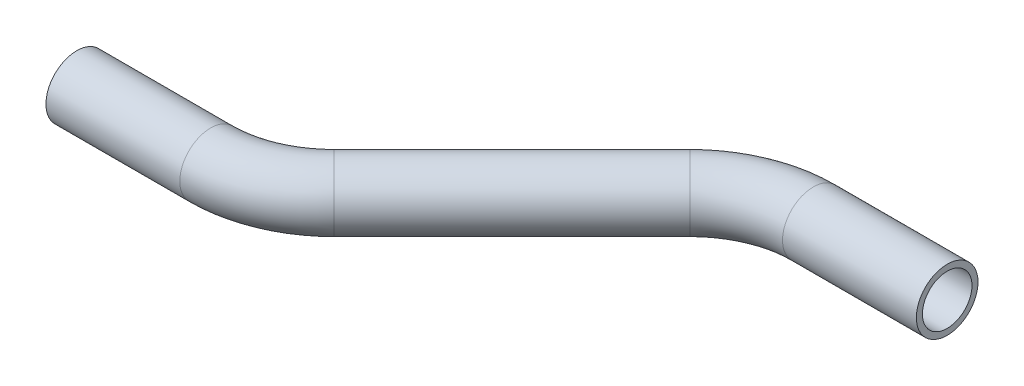
from build123d import *

# Parameters (mm, degrees)
SKETCH3_R   = 6.35
SKETCH3_R_2 = 5.1054


with BuildPart() as part:
    # Sweep1: sweep along a path in Sketch2
    with BuildLine(Plane(origin=(0, 0, 0), x_dir=(1, 0, 0), z_dir=(0, 1, 0))) as sweep1_path:
        Line((0, 0), (27.578975516, 0))
        ThreePointArc((27.578975516, 0), (37.299134698, 1.933459874), (45.539487758, 7.439487758))
        Line((45.539487758, 7.439487758), (82.222512242, 44.122512242))
        ThreePointArc((82.222512242, 44.122512242), (90.462865302, 49.628540126), (100.183024484, 51.562))
        Line((100.183024484, 51.562), (127.762, 51.562))
    # Sketch3 → Sweep1 (sweep)
    with BuildSketch(Plane(origin=(0, 0, 0), x_dir=(0, 0, -1), z_dir=(1, 0, 0))):
        Circle(SKETCH3_R)
        Circle(SKETCH3_R_2, mode=Mode.SUBTRACT)
    sweep(path=sweep1_path.line)


solid = part.part
